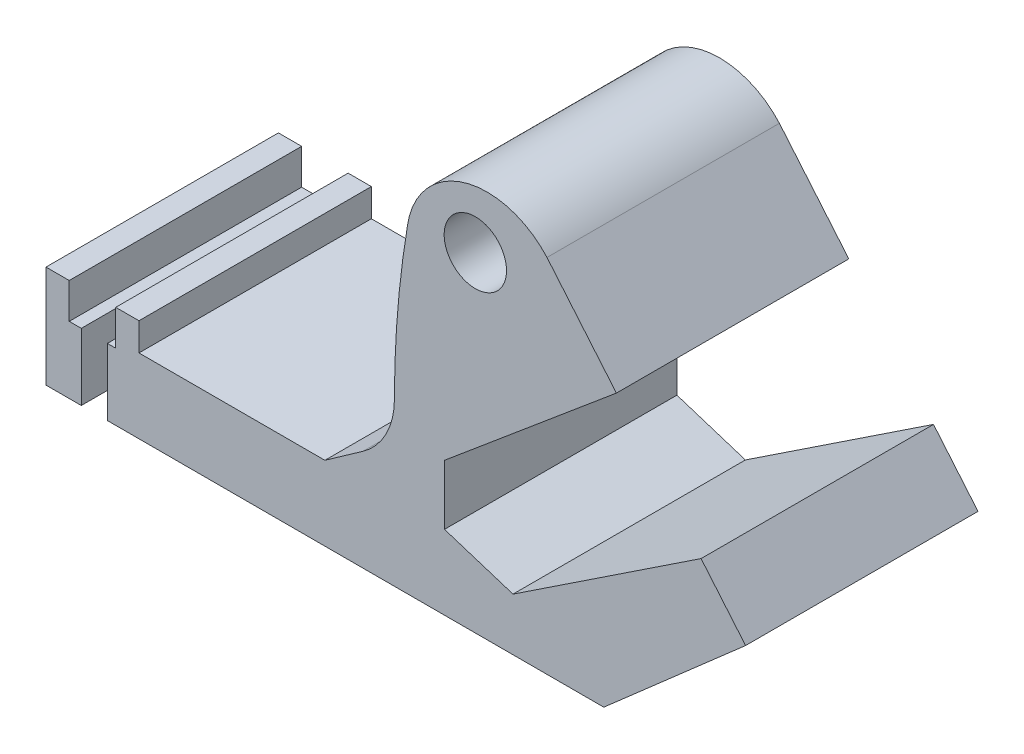
from build123d import *

# Parameters (mm, degrees)
BOSS_EXTRUDE1_DEPTH = 50
SKETCH2_R           = 6.706955273
CUT_EXTRUDE1_DEPTH  = 50
SKETCH3_W           = 5.615900211
SKETCH3_H           = 17.85801338
CUT_EXTRUDE3_DEPTH  = 50


with BuildPart() as part:
    # Sketch1 → Boss-Extrude1 (new body)
    with BuildSketch(Plane.XY):
        with BuildLine():
            Line((-80.136986301, 22), (-80.136986301, 0))
            Line((-80.136986301, 0), (39.863013699, 0))
            Line((39.863013699, 0), (70.368770652, 26.734309258))
            Line((70.368770652, 26.734309258), (60.793116967, 38.153404294))
            Line((60.793116967, 38.153404294), (20.329079656, 11.29806257))
            Line((20.329079656, 11.29806257), (5.596910467, 16))
            Line((5.596910467, 16), (5.596910467, 28.866371282))
            Line((5.596910467, 28.866371282), (42.576894843, 59.876492709))
            Line((42.576894843, 59.876492709), (28.374143533, 76.813463522))
            Line((28.374143533, 76.813463522), (27.644448799, 77.683634248))
            ThreePointArc((27.644448799, 77.683634248), (9.775633658, 82.708091174), (-2.362906797, 68.665457606))
            ThreePointArc((-2.362906797, 68.665457606), (-4.475191094, 51.810848299), (-5.180910018, 34.839061104))
            ThreePointArc((-5.180910018, 34.839061104), (-6.977338503, 27.473020361), (-11.963229546, 21.761050295))
            Line((-11.963229546, 21.761050295), (-20.136986301, 16))
            Line((-20.136986301, 16), (-60.136986301, 16))
            Line((-60.136986301, 16), (-60.136986301, 22))
            Line((-60.136986301, 22), (-65.136986301, 22))
            Line((-65.136986301, 22), (-65.136986301, 14.383561644))
            Line((-65.136986301, 14.383561644), (-75.136986301, 14.383561644))
            Line((-75.136986301, 14.383561644), (-75.136986301, 22))
            Line((-75.136986301, 22), (-80.136986301, 22))
        make_face()
    extrude(amount=BOSS_EXTRUDE1_DEPTH)

    # Sketch2 → Cut-Extrude1 (cut)
    with BuildSketch(Plane.XY.offset(50)):
        with Locations((12.231016626, 70.8693701)):
            Circle(SKETCH2_R)
    extrude(amount=-CUT_EXTRUDE1_DEPTH, mode=Mode.SUBTRACT)

    # Sketch3 → Cut-Extrude3 (cut)
    with BuildSketch(Plane.XY.offset(50)):
        with Locations((-69.734384067, 5.454554954)):
            Rectangle(SKETCH3_W, SKETCH3_H)
    extrude(amount=-CUT_EXTRUDE3_DEPTH, mode=Mode.SUBTRACT)


solid = part.part
